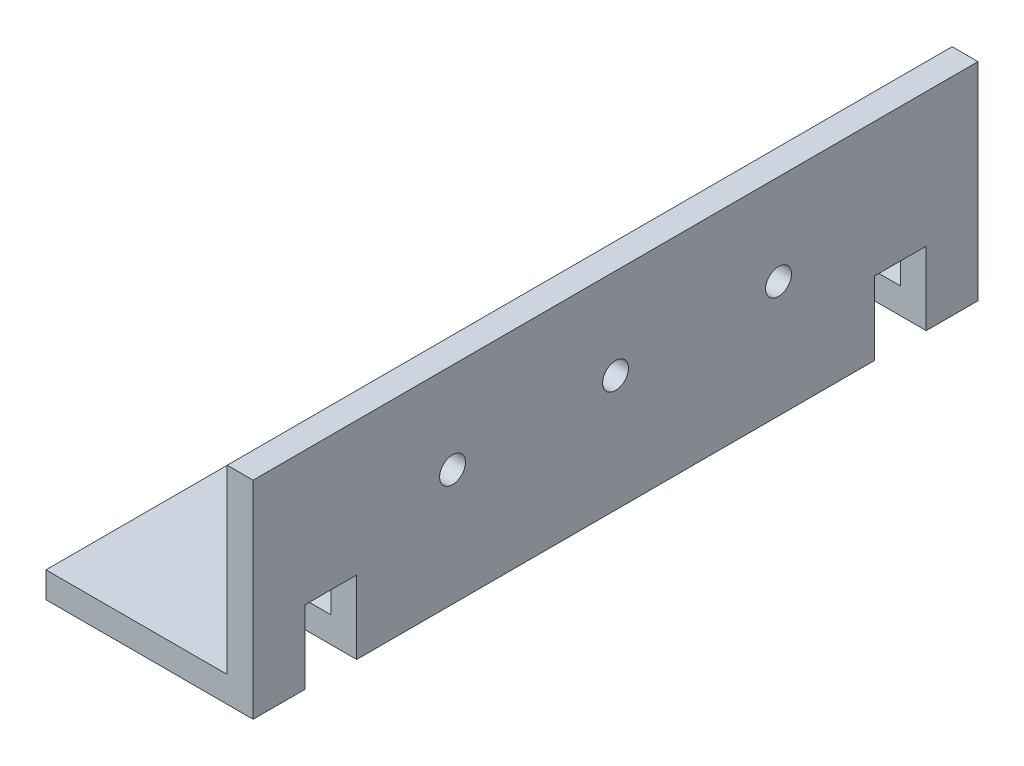
from build123d import *

# Parameters (mm, degrees)
BOSS_EXTRUDE1_DEPTH     = 88.9
SKETCH2_W               = 6.35
SKETCH2_H               = 6.35
CUT_EXTRUDE4_DEPTH      = 18.960512242
CUT_EXTRUDE4_DEPTH_BACK = 18.960512242
SKETCH3_R               = 1.5875
CUT_EXTRUDE5_DEPTH      = 4.175


with BuildPart() as part:
    # Sketch1 → Boss-Extrude1 (new body)
    with BuildSketch(Plane.XY):
        Polygon((0, 0), (0, 25.4), (-3.175, 25.4), (-3.175, 3.175), (-25.4, 3.175), (-25.4, 0), align=None)
    extrude(amount=BOSS_EXTRUDE1_DEPTH)

    # Sketch2 → Cut-Extrude4 (cut, two sides)
    with BuildSketch(Plane(origin=(0, 0, 0), x_dir=(0, 0, -1), z_dir=(0.707106781, 0.707106781, 0))) as cut_extrude4_sk:
        with Locations((-79.375, 3.175)):
            Rectangle(SKETCH2_W, SKETCH2_H)
        with Locations((-9.525, 3.175)):
            Rectangle(SKETCH2_W, SKETCH2_H)
    extrude(amount=CUT_EXTRUDE4_DEPTH, mode=Mode.SUBTRACT)
    extrude(cut_extrude4_sk.sketch, amount=-CUT_EXTRUDE4_DEPTH_BACK, mode=Mode.SUBTRACT)

    # Sketch3 → Cut-Extrude5 (cut, through all)
    with BuildSketch(Plane.ZY.offset(3.175)):
        with Locations((44.45, 14.2875)):
            Circle(SKETCH3_R)
        with Locations((24.4602, 14.2875)):
            Circle(SKETCH3_R)
        with Locations((64.4398, 14.2875)):
            Circle(SKETCH3_R)
    extrude(amount=-CUT_EXTRUDE5_DEPTH, mode=Mode.SUBTRACT)


solid = part.part
